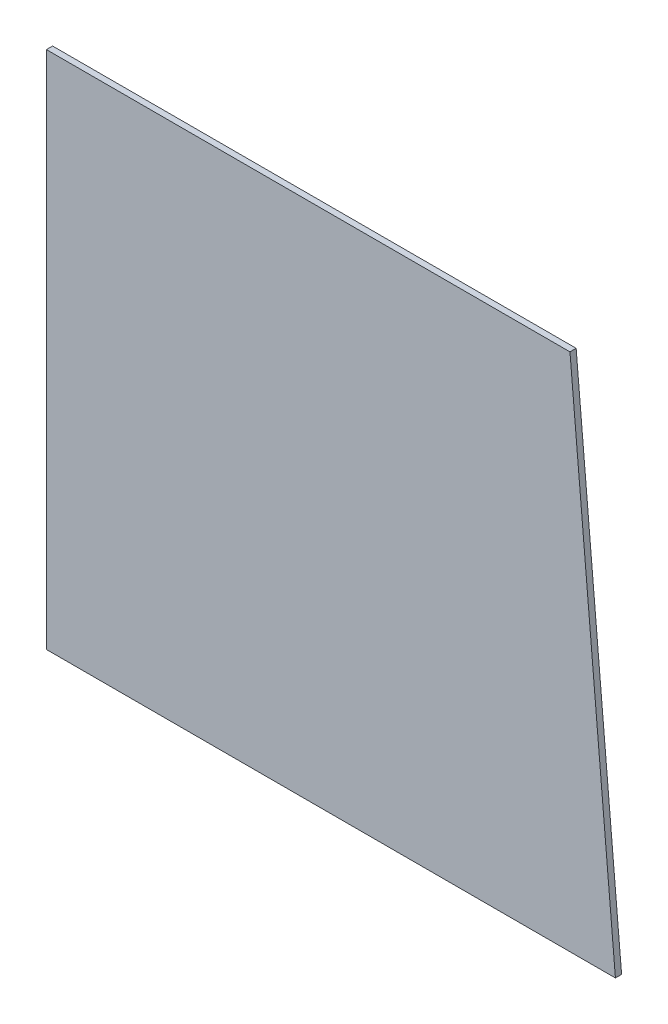
from build123d import *

# Parameters (mm, degrees)
BOSS_EXTRUDE2_DEPTH = 1.5875


with BuildPart() as part:
    # Sketch1 → Boss-Extrude2 (new body)
    with BuildSketch(Plane.XY):
        Polygon((146.05, 0), (134.383386719, 133.35), (0, 133.35), (0, 0), align=None)
    extrude(amount=BOSS_EXTRUDE2_DEPTH)


solid = part.part
